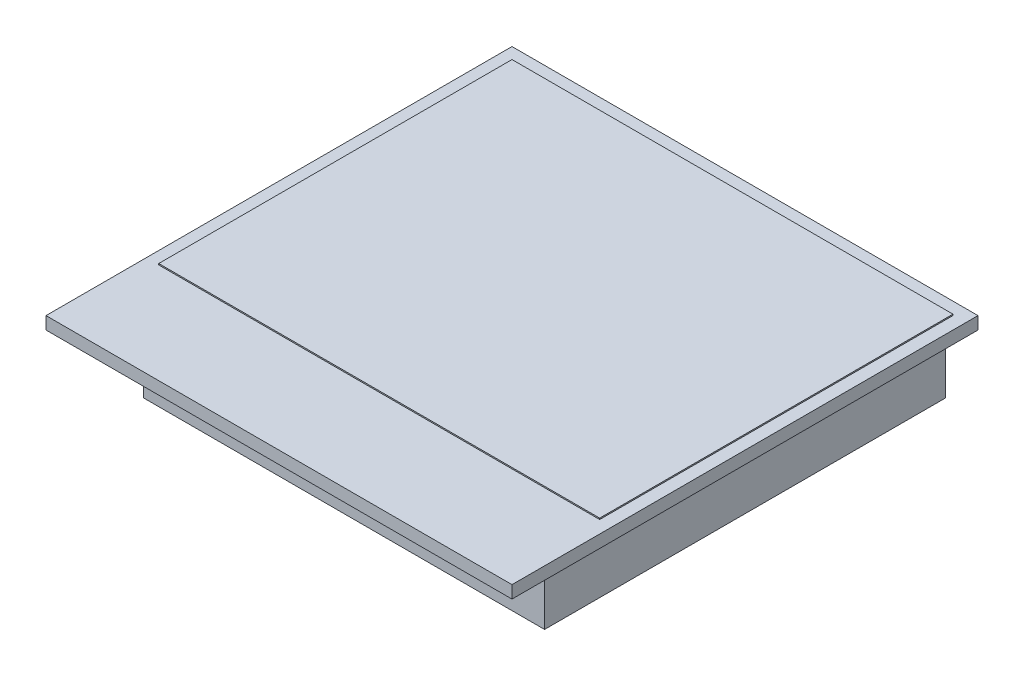
from build123d import *

# Parameters (mm, degrees)
SKETCH1_W         = 18.6
SKETCH1_H         = 18.6
GLASS_DEPTH       = 0.5
SKETCH2_W         = 17.6
SKETCH2_H         = 14.1
DISPLAY_DEPTH     = 0.05
SKETCH3_W         = 16
SKETCH3_H         = 16
STICKY_FOAM_DEPTH = 3


with BuildPart() as part:
    # Sketch1 → glass (new body)
    with BuildSketch(Plane(origin=(0, 0, 0), x_dir=(1, 0, 0), z_dir=(0, 1, 0))):
        with Locations((0, 9.3)):
            Rectangle(SKETCH1_W, SKETCH1_H)
    extrude(amount=GLASS_DEPTH)


with BuildPart() as body_2:
    # Sketch2 → display (new body)
    with BuildSketch(Plane(origin=(0, 0.5, 0), x_dir=(1, 0, 0), z_dir=(0, 1, 0))):
        with Locations((0, 11.05)):
            Rectangle(SKETCH2_W, SKETCH2_H)
    extrude(amount=DISPLAY_DEPTH)


with BuildPart() as body_3:
    # Sketch3 → sticky_foam (new body)
    with BuildSketch(Plane.XZ):
        with Locations((0, -10.6)):
            Rectangle(SKETCH3_W, SKETCH3_H)
    extrude(amount=STICKY_FOAM_DEPTH)


solid = Compound([part.part, body_2.part, body_3.part])
